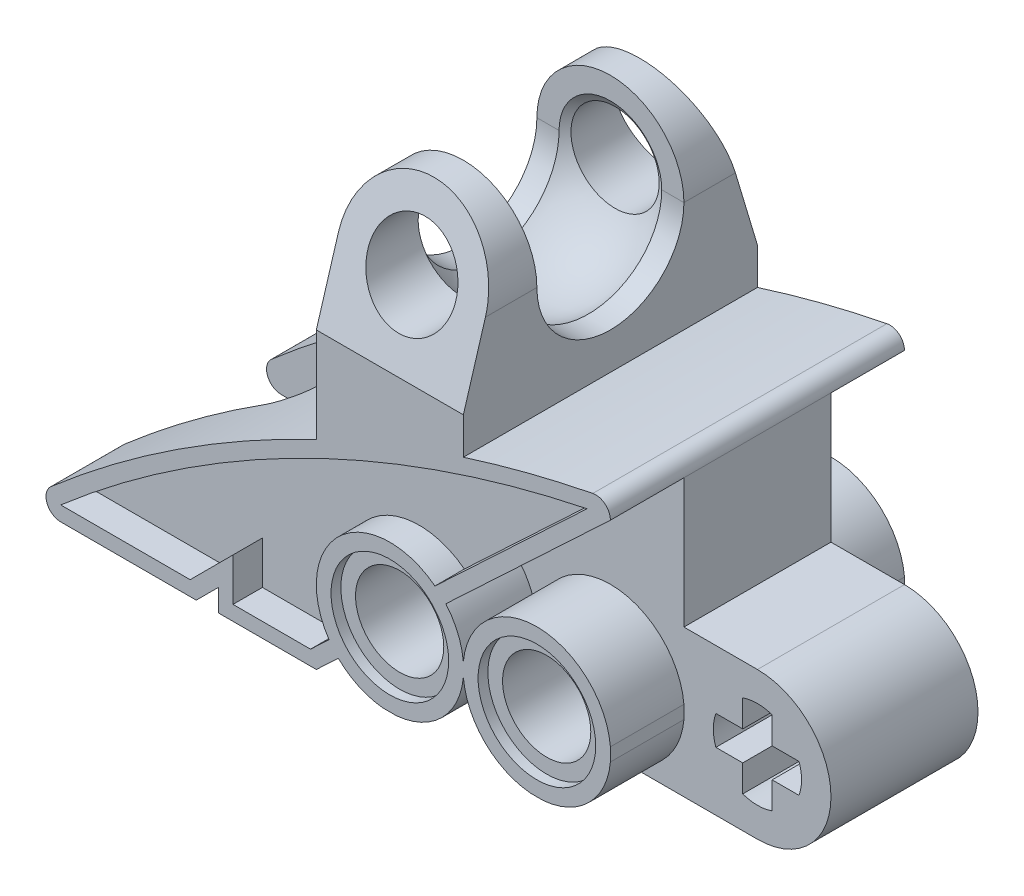
from build123d import *

# Parameters (mm, degrees)
BOSS_EXTRUDE1_DEPTH = 10
SKETCH2_W           = 5
SKETCH2_H           = 10
BOSS_EXTRUDE3_DEPTH = 5
SKETCH4_W           = 5
SKETCH4_H           = 5
BOSS_EXTRUDE4_DEPTH = 5
CUT_EXTRUDE2_DEPTH  = 5
CUT_EXTRUDE3_DEPTH  = 10
SKETCH8_R           = 2.5
SKETCH8_W           = 5
SKETCH8_H           = 2.5
CUT_EXTRUDE4_DEPTH  = 10
CUT_EXTRUDE5_DEPTH  = 10
SKETCH9_W           = 1
SKETCH9_H           = 1
CUT_EXTRUDE7_DEPTH  = 5
CUT_EXTRUDE8_DEPTH  = 10
CUT_EXTRUDE9_DEPTH  = 3.333333333
CUT_EXTRUDE10_DEPTH = 3.333333333
CUT_EXTRUDE11_DEPTH = 10
CUT_EXTRUDE12_DEPTH = 10
CUT_EXTRUDE19_DEPTH = 2.5
SKETCH15_10_R       = 1.5
CUT_EXTRUDE20_DEPTH = 10
SKETCH15_11_R       = 2
SKETCH15_11_R_2     = 1.5
CUT_EXTRUDE21_DEPTH = 0.333333333
CUT_EXTRUDE23_DEPTH = 2.5
SKETCH16_4_R        = 2
SKETCH16_4_R_2      = 1.5
CUT_EXTRUDE24_DEPTH = 0.333333333
CUT_EXTRUDE25_DEPTH = 1
CUT_EXTRUDE26_DEPTH = 10


with BuildPart() as part:
    # Sketch1 → Boss-Extrude1 (new body)
    with BuildSketch(Plane(origin=(0, 0, 0), x_dir=(1, 0, 0), z_dir=(0, 1, 0))):
        with BuildLine():
            ThreePointArc((-4.333333333, 2.5), (-3.626226552, 2.207106781), (-3.333333333, 1.5))
            Line((-3.333333333, 1.5), (-3.333333333, -1.5))
            ThreePointArc((-3.333333333, -1.5), (-3.626226552, -2.207106781), (-4.333333333, -2.5))
            Line((-4.333333333, -2.5), (-10, -2.5))
            Line((-10, -2.5), (-10, -5))
            Line((-10, -5), (10, -5))
            Line((10, -5), (10, -2.5))
            Line((10, -2.5), (10, 2.5))
            Line((10, 2.5), (10, 5))
            Line((10, 5), (-10, 5))
            Line((-10, 5), (-10, 2.5))
            Line((-10, 2.5), (-4.333333333, 2.5))
        make_face()
        with BuildLine():
            Line((-3.333333333, -1.5), (-3.333333333, 1.5))
            ThreePointArc((-3.333333333, 1.5), (-3.626226552, 2.207106781), (-4.333333333, 2.5))
            Line((-4.333333333, 2.5), (-10, 2.5))
            Line((-10, 2.5), (-10, -2.5))
            Line((-10, -2.5), (-4.333333333, -2.5))
            ThreePointArc((-4.333333333, -2.5), (-3.626226552, -2.207106781), (-3.333333333, -1.5))
        make_face()
    extrude(amount=BOSS_EXTRUDE1_DEPTH)

    # Sketch2 → Boss-Extrude3 (add)
    with BuildSketch(Plane(origin=(0, 10, 0), x_dir=(1, 0, 0), z_dir=(0, 1, 0))):
        with Locations((2.5, 0)):
            Rectangle(SKETCH2_W, SKETCH2_H)
    extrude(amount=BOSS_EXTRUDE3_DEPTH)

    # Sketch4 → Boss-Extrude4 (add)
    with BuildSketch(Plane(origin=(10, 0, 0), x_dir=(0, 0, -1), z_dir=(1, 0, 0))):
        with Locations((0, 2.5)):
            Rectangle(SKETCH4_W, SKETCH4_H)
    extrude(amount=BOSS_EXTRUDE4_DEPTH)

    # Sketch6 → Cut-Extrude2 (cut)
    with BuildSketch(Plane(origin=(5, 0, 0), x_dir=(0, 0, -1), z_dir=(1, 0, 0))):
        Polygon((-5, 10), (-3.5, 15), (-5, 15), align=None)
        Polygon((5, 10), (3.5, 15), (5, 15), align=None)
    extrude(amount=-CUT_EXTRUDE2_DEPTH, mode=Mode.SUBTRACT)

    # Sketch5 → Cut-Extrude3 (cut)
    with BuildSketch(Plane.XY.offset(5)):
        with BuildLine():
            ThreePointArc((4, 12.5), (2.5, 14), (1, 12.5))
            Line((1, 12.5), (2.5, 12.5))
            Line((2.5, 12.5), (2.5, 11))
            ThreePointArc((2.5, 11), (3.560660172, 11.439339828), (4, 12.5))
        make_face()
        with BuildLine():
            ThreePointArc((2.5, 15), (4.267766953, 14.267766953), (5, 12.5))
            Line((5, 12.5), (5, 15))
            Line((5, 15), (2.5, 15))
        make_face()
        with BuildLine():
            ThreePointArc((0, 12.5), (0.732233047, 14.267766953), (2.5, 15))
            Line((2.5, 15), (0, 15))
            Line((0, 15), (0, 12.5))
        make_face()
    extrude(amount=-CUT_EXTRUDE3_DEPTH, mode=Mode.SUBTRACT)

    # Sketch7 → Cut-Revolve1 (revolve, cut)
    with BuildSketch(Plane(origin=(0, 12.5, 0), x_dir=(1, 0, 0), z_dir=(0, 1, 0))):
        with BuildLine():
            ThreePointArc((2.5, -2.939695398), (5.5, 0.060304602), (2.5, 3.060304602))
            Line((2.5, 3.060304602), (2.5, -2.939695398))
        make_face()
    revolve(axis=Axis((2.5, 12.5, -4.25), (0, 0, 1)), mode=Mode.SUBTRACT)

    # Sketch8 → Cut-Extrude4 (cut)
    with BuildSketch(Plane(origin=(5, 0, 0), x_dir=(0, 0, -1), z_dir=(1, 0, 0))):
        with Locations((0, 12.5)):
            Circle(SKETCH8_R)
        with Locations((0, 13.75)):
            Rectangle(SKETCH8_W, SKETCH8_H)
    extrude(amount=-CUT_EXTRUDE4_DEPTH, mode=Mode.SUBTRACT)

    # Sketch5_4 → Cut-Extrude5 (cut)
    with BuildSketch(Plane.XY.offset(5)):
        with BuildLine():
            ThreePointArc((4, 12.5), (2.5, 14), (1, 12.5))
            Line((1, 12.5), (2.5, 12.5))
            Line((2.5, 12.5), (2.5, 11))
            ThreePointArc((2.5, 11), (3.560660172, 11.439339828), (4, 12.5))
        make_face()
        with BuildLine():
            Line((2.5, 12.5), (1, 12.5))
            ThreePointArc((1, 12.5), (1.439339828, 11.439339828), (2.5, 11))
            Line((2.5, 11), (2.5, 12.5))
        make_face()
    extrude(amount=-CUT_EXTRUDE5_DEPTH, mode=Mode.SUBTRACT)

    # Sketch9 → Cut-Extrude7 (cut)
    with BuildSketch(Plane.XY.offset(2.5)):
        with BuildLine():
            Line((15, 5), (12.5, 5))
            ThreePointArc((12.5, 5), (14.267766953, 4.267766953), (15, 2.5))
            Line((15, 2.5), (15, 5))
        make_face()
        with BuildLine():
            Line((15, 0), (15, 2.5))
            ThreePointArc((15, 2.5), (14.267766953, 0.732233047), (12.5, 0))
            Line((12.5, 0), (15, 0))
        make_face()
        with BuildLine():
            Line((13, 3), (13, 2))
            Line((13, 2), (13.914213562, 2))
            ThreePointArc((13.914213562, 2), (13.978397839, 2.246347032), (14, 2.5))
            ThreePointArc((14, 2.5), (13.978397839, 2.753652968), (13.914213562, 3))
            Line((13.914213562, 3), (13, 3))
        make_face()
        with BuildLine():
            Line((12, 3.914213562), (12, 3))
            Line((12, 3), (13, 3))
            Line((13, 3), (13, 3.914213562))
            ThreePointArc((13, 3.914213562), (12.753652968, 3.978397839), (12.5, 4))
            ThreePointArc((12.5, 4), (12.246347032, 3.978397839), (12, 3.914213562))
        make_face()
        with Locations((12.5, 2.5)):
            Rectangle(SKETCH9_W, SKETCH9_H)
        with BuildLine():
            ThreePointArc((11, 2.5), (11.021602161, 2.246347032), (11.085786438, 2))
            Line((11.085786438, 2), (12, 2))
            Line((12, 2), (12, 3))
            Line((12, 3), (11.085786438, 3))
            ThreePointArc((11.085786438, 3), (11.021602161, 2.753652968), (11, 2.5))
        make_face()
        with BuildLine():
            Line((13, 2), (12, 2))
            Line((12, 2), (12, 1.085786438))
            ThreePointArc((12, 1.085786438), (12.246347032, 1.021602161), (12.5, 1))
            ThreePointArc((12.5, 1), (12.753652968, 1.021602161), (13, 1.085786438))
            Line((13, 1.085786438), (13, 2))
        make_face()
    extrude(amount=-CUT_EXTRUDE7_DEPTH, mode=Mode.SUBTRACT)

    # Sketch10 → Cut-Extrude8 (cut)
    with BuildSketch(Plane.XY.offset(5)):
        with BuildLine():
            ThreePointArc((-10, 0), (-6.796912004, 2.669496411), (-3.333333333, 4.991049035))
            Line((-3.333333333, 4.991049035), (-3.333333333, 10))
            Line((-3.333333333, 10), (-10, 10))
            Line((-10, 10), (-10, 0))
        make_face()
        Polygon((-3.333333333, 4.991049035), (0, 10), (-3.333333333, 10), align=None)
        with BuildLine():
            Line((5, 10), (5, 8.750783168))
            ThreePointArc((5, 8.750783168), (7.479860086, 9.456001746), (10, 10))
            Line((10, 10), (5, 10))
        make_face()
    extrude(amount=-CUT_EXTRUDE8_DEPTH, mode=Mode.SUBTRACT)

    # Sketch10_3 → Cut-Extrude9 (cut)
    with BuildSketch(Plane.XY.offset(5)):
        with BuildLine():
            ThreePointArc((-3.333333333, 4.991049035), (-1.687735767, 5.921749898), (0, 6.773655662))
            Line((0, 6.773655662), (0, 10))
            Line((0, 10), (-3.333333333, 4.991049035))
        make_face()
    extrude(amount=-CUT_EXTRUDE9_DEPTH, mode=Mode.SUBTRACT)

    # Sketch13 → Cut-Extrude10 (cut)
    with BuildSketch(Plane(origin=(0, 0, -5), x_dir=(-1, 0, 0), z_dir=(0, 0, -1))):
        with BuildLine():
            Line((3.333333333, 4.991049035), (0, 10))
            Line((0, 10), (0, 6.773655662))
            ThreePointArc((0, 6.773655662), (1.687735767, 5.921749898), (3.333333333, 4.991049035))
        make_face()
    extrude(amount=-CUT_EXTRUDE10_DEPTH, mode=Mode.SUBTRACT)

    # Sketch1_5 → Cut-Extrude11 (cut)
    with BuildSketch(Plane(origin=(0, 0, 0), x_dir=(1, 0, 0), z_dir=(0, 1, 0))):
        with BuildLine():
            Line((-3.333333333, -1.5), (-3.333333333, 1.5))
            ThreePointArc((-3.333333333, 1.5), (-3.626226552, 2.207106781), (-4.333333333, 2.5))
            Line((-4.333333333, 2.5), (-10, 2.5))
            Line((-10, 2.5), (-10, -2.5))
            Line((-10, -2.5), (-4.333333333, -2.5))
            ThreePointArc((-4.333333333, -2.5), (-3.626226552, -2.207106781), (-3.333333333, -1.5))
        make_face()
    extrude(amount=CUT_EXTRUDE11_DEPTH, mode=Mode.SUBTRACT)

    # Sketch14 → Cut-Extrude12 (cut)
    with BuildSketch(Plane.XY.offset(5)):
        with BuildLine():
            Line((-10, 0), (-8.69256602, 0))
            ThreePointArc((-8.69256602, 0), (-9.161037567, 0.32525902), (-9.020010728, 0.87786236))
            ThreePointArc((-9.020010728, 0.87786236), (-9.513614947, 0.442960687), (-10, 0))
        make_face()
        with BuildLine():
            ThreePointArc((9.402841006, 9.886414874), (9.817348785, 9.782325895), (10, 9.395945579))
            Line((10, 9.395945579), (10, 10))
            ThreePointArc((10, 10), (9.701204736, 9.944341805), (9.402841006, 9.886414874))
        make_face()
    extrude(amount=-CUT_EXTRUDE12_DEPTH, mode=Mode.SUBTRACT)

    # Sketch15 → Cut-Extrude19 (cut)
    with BuildSketch(Plane.XY.offset(5)):
        with BuildLine():
            Line((10, 9.395945579), (4.402826785, 4.136872086))
            ThreePointArc((4.402826785, 4.136872086), (4.812010532, 3.477091244), (5, 2.723830293))
            ThreePointArc((5, 2.723830293), (7.5, 5.01), (10, 2.723830293))
            Line((10, 2.723830293), (10, 9.395945579))
        make_face()
        with BuildLine():
            ThreePointArc((10, 2.276169707), (9.274838021, 0.725161979), (7.723830293, 0))
            Line((7.723830293, 0), (10, 0))
            Line((10, 0), (10, 2.276169707))
        make_face()
    extrude(amount=-CUT_EXTRUDE19_DEPTH, mode=Mode.SUBTRACT)

    # Sketch15_10 → Cut-Extrude20 (cut)
    with BuildSketch(Plane.XY.offset(5)):
        with BuildLine():
            ThreePointArc((5, 2.276169707), (4.274838021, 0.725161979), (2.723830293, 0))
            Line((2.723830293, 0), (7.276169707, 0))
            ThreePointArc((7.276169707, 0), (5.725161979, 0.725161979), (5, 2.276169707))
        make_face()
        with BuildLine():
            Line((0.747894166, 0.702717288), (0, 0))
            Line((0, 0), (2.276169707, 0))
            ThreePointArc((2.276169707, 0), (1.451413432, 0.219525004), (0.747894166, 0.702717288))
        make_face()
        with Locations((7.5, 2.5)):
            Circle(SKETCH15_10_R)
        with BuildLine():
            ThreePointArc((3.665576836, 3.444156046), (1.472870312, 3.593162662), (1.485144115, 1.395433328))
            Line((1.485144115, 1.395433328), (3.665576836, 3.444156046))
        make_face()
        with BuildLine():
            Line((3.665576836, 3.444156046), (1.485144115, 1.395433328))
            ThreePointArc((1.485144115, 1.395433328), (3.103206504, 1.126631181), (4, 2.5))
            ThreePointArc((4, 2.5), (3.913924548, 3.000816706), (3.665576836, 3.444156046))
        make_face()
    extrude(amount=-CUT_EXTRUDE20_DEPTH, mode=Mode.SUBTRACT)

    # Sketch15_11 → Cut-Extrude21 (cut)
    with BuildSketch(Plane.XY.offset(5)):
        with Locations((7.5, 2.5)):
            Circle(SKETCH15_11_R)
        with Locations((7.5, 2.5)):
            Circle(SKETCH15_11_R_2, mode=Mode.SUBTRACT)
        with BuildLine():
            ThreePointArc((4.03070227, 3.787225917), (1.13049375, 3.957550215), (1.120018681, 1.052363457))
            Line((1.120018681, 1.052363457), (1.485144115, 1.395433328))
            ThreePointArc((1.485144115, 1.395433328), (1.472870312, 3.593162662), (3.665576836, 3.444156046))
            Line((3.665576836, 3.444156046), (4.03070227, 3.787225917))
        make_face()
        with BuildLine():
            Line((1.485144115, 1.395433328), (1.120018681, 1.052363457))
            ThreePointArc((1.120018681, 1.052363457), (3.28741265, 0.661527449), (4.5, 2.5))
            ThreePointArc((4.5, 2.5), (4.379016304, 3.185053086), (4.03070227, 3.787225917))
            Line((4.03070227, 3.787225917), (3.665576836, 3.444156046))
            ThreePointArc((3.665576836, 3.444156046), (3.913924548, 3.000816706), (4, 2.5))
            ThreePointArc((4, 2.5), (3.103206504, 1.126631181), (1.485144115, 1.395433328))
        make_face()
    extrude(amount=-CUT_EXTRUDE21_DEPTH, mode=Mode.SUBTRACT)

    # Sketch16 → Cut-Extrude23 (cut)
    with BuildSketch(Plane(origin=(0, 0, -5), x_dir=(-1, 0, 0), z_dir=(0, 0, -1))):
        with BuildLine():
            ThreePointArc((-10, 2.723830293), (-7.5, 5.01), (-5, 2.723830293))
            ThreePointArc((-5, 2.723830293), (-4.812010532, 3.477091244), (-4.402826785, 4.136872086))
            Line((-4.402826785, 4.136872086), (-10, 9.395945579))
            Line((-10, 9.395945579), (-10, 2.723830293))
        make_face()
        with BuildLine():
            Line((-10, 0), (-7.723830293, 0))
            ThreePointArc((-7.723830293, 0), (-9.274838021, 0.725161979), (-10, 2.276169707))
            Line((-10, 2.276169707), (-10, 0))
        make_face()
    extrude(amount=-CUT_EXTRUDE23_DEPTH, mode=Mode.SUBTRACT)

    # Sketch16_4 → Cut-Extrude24 (cut)
    with BuildSketch(Plane(origin=(0, 0, -5), x_dir=(-1, 0, 0), z_dir=(0, 0, -1))):
        with Locations((-7.5, 2.5)):
            Circle(SKETCH16_4_R)
        with Locations((-7.5, 2.5)):
            Circle(SKETCH16_4_R_2, mode=Mode.SUBTRACT)
        with BuildLine():
            ThreePointArc((-4.03070227, 3.787225917), (-3.86950625, 1.042449785), (-1.120018681, 1.052363457))
            Line((-1.120018681, 1.052363457), (-1.485144115, 1.395433328))
            ThreePointArc((-1.485144115, 1.395433328), (-3.527129688, 1.406837338), (-3.665576836, 3.444156046))
            Line((-3.665576836, 3.444156046), (-4.03070227, 3.787225917))
        make_face()
        with BuildLine():
            Line((-1.485144115, 1.395433328), (-1.120018681, 1.052363457))
            ThreePointArc((-1.120018681, 1.052363457), (-0.661527449, 1.71258735), (-0.5, 2.5))
            ThreePointArc((-0.5, 2.5), (-1.814946914, 4.379016304), (-4.03070227, 3.787225917))
            Line((-4.03070227, 3.787225917), (-3.665576836, 3.444156046))
            ThreePointArc((-3.665576836, 3.444156046), (-1.999183294, 3.913924548), (-1, 2.5))
            ThreePointArc((-1, 2.5), (-1.126631181, 1.896793496), (-1.485144115, 1.395433328))
        make_face()
    extrude(amount=-CUT_EXTRUDE24_DEPTH, mode=Mode.SUBTRACT)

    # Sketch17 → Cut-Extrude25 (cut)
    with BuildSketch(Plane.XY.offset(5)):
        with BuildLine():
            Line((-0.19804575, 0.5), (0.433345702, 1.093251972))
            ThreePointArc((0.433345702, 1.093251972), (0.788117187, 4.321937769), (4.032622123, 4.47511251))
            Line((4.032622123, 4.47511251), (9.206756271, 9.336700797))
            ThreePointArc((9.206756271, 9.336700797), (-0.310327721, 6.067702926), (-8.69256602, 0.5))
            Line((-8.69256602, 0.5), (-4.290440115, 0.5))
            Line((-4.290440115, 0.5), (-3.686886724, 1.103553391))
            Line((-3.686886724, 1.103553391), (-2.833333333, 1.957106781))
            Line((-2.833333333, 1.957106781), (-2.833333333, 0.75))
            Line((-2.833333333, 0.75), (-2.833333333, 0.5))
            Line((-2.833333333, 0.5), (-0.19804575, 0.5))
        make_face()
    cut_extrude25 = extrude(amount=-CUT_EXTRUDE25_DEPTH, mode=Mode.SUBTRACT)

    # Mirror1: Cut-Extrude25 across plane
    add(cut_extrude25.mirror(Plane.XY), mode=Mode.SUBTRACT)

    # Sketch17_3 → Cut-Extrude26 (cut)
    with BuildSketch(Plane.XY.offset(5)):
        Polygon((-4.083333333, 0), (-3.333333333, 0), (-3.333333333, 0.75), align=None)
    extrude(amount=-CUT_EXTRUDE26_DEPTH, mode=Mode.SUBTRACT)


solid = part.part
